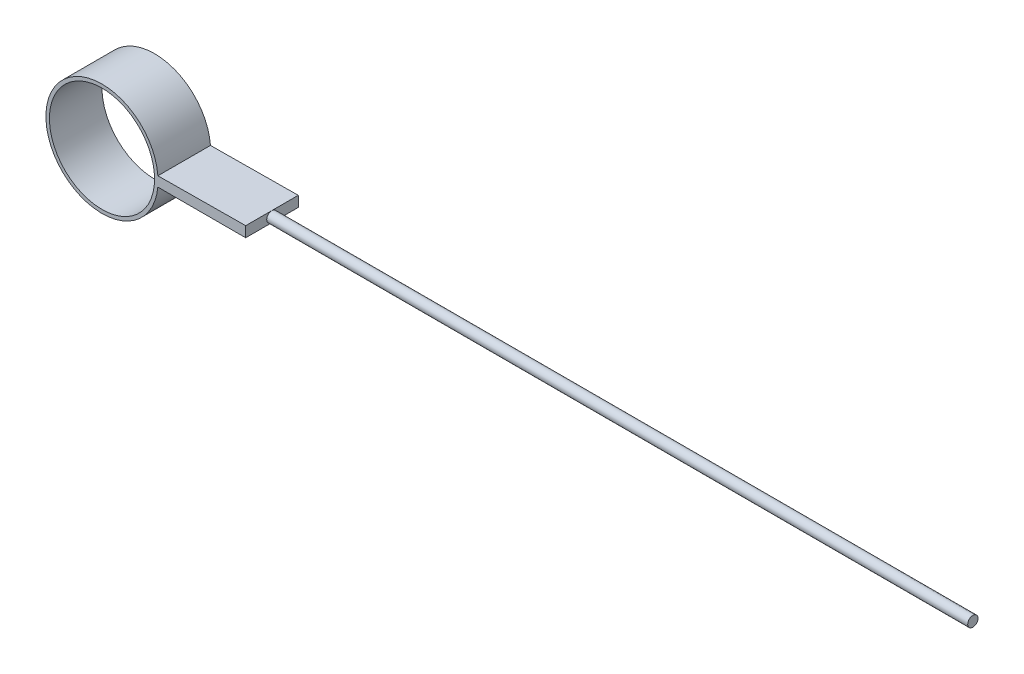
from build123d import *

# Parameters (mm, degrees)
SKETCH_1_R      = 3
EXTRUDE_1_DEPTH = 3
SKETCH_2_R      = 0.293076877
EXTRUDE_2_DEPTH = 40
SCALE_1_SCALE   = 3.5


with BuildPart() as part:
    # 草图1 → 凸台-拉伸1 (new body)
    with BuildSketch(Plane.XY):
        with BuildLine():
            Line((8.2, 0.3), (3.189519169, 0.258780744))
            ThreePointArc((3.189519169, 0.258780744), (-3.199933121, 0.020688637), (3.185906464, -0.3))
            Line((3.185906464, -0.3), (8.2, -0.3))
            Line((8.2, -0.3), (8.2, 0.3))
        make_face()
        Circle(SKETCH_1_R, mode=Mode.SUBTRACT)
    extrude(amount=EXTRUDE_1_DEPTH)

    # 草图2 → 凸台-拉伸2 (add)
    with BuildSketch(Plane(origin=(8.2, 0, 0), x_dir=(0, 0, -1), z_dir=(1, 0, 0))):
        with Locations((-1.506058585, 0)):
            Circle(SKETCH_2_R)
    extrude(amount=EXTRUDE_2_DEPTH)


with BuildPart() as part_1:
    # 缩放比例1: scaled about (11.360396765, -0.00284627, 1.502097409)
    add(part.part.scale(SCALE_1_SCALE).moved(Location((-28.400991913, 0.007115675, -3.755243523))))


solid = part_1.part
